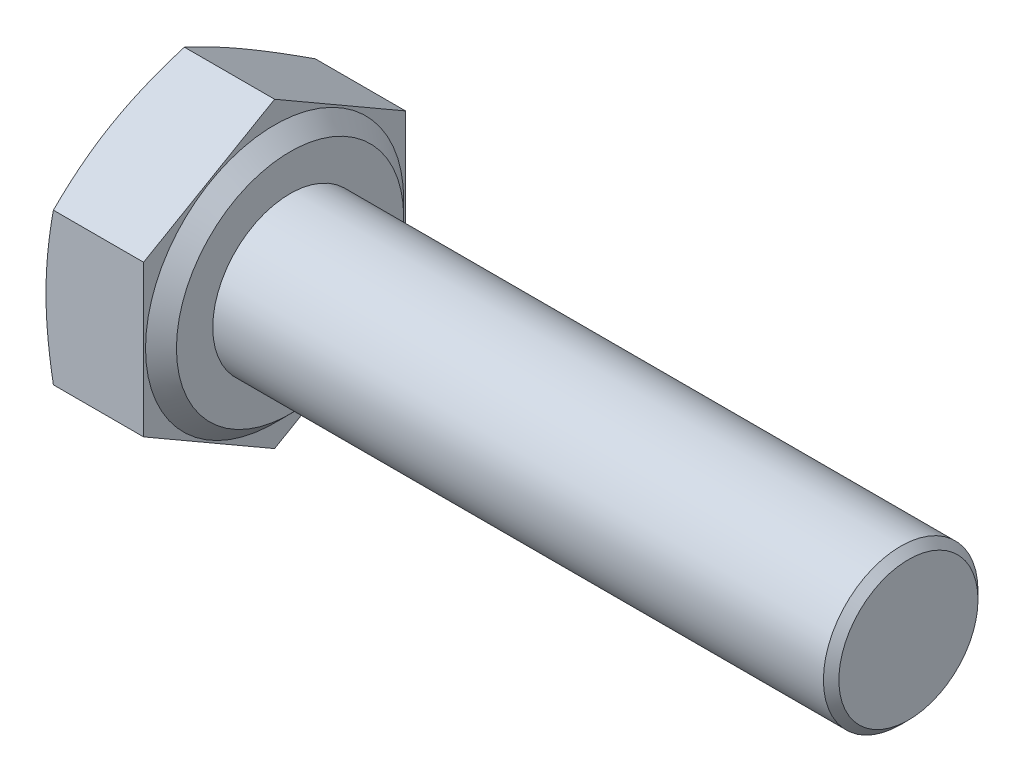
from build123d import *

# Parameters (mm, degrees)
BASEHEAD_DEPTH = 2.925
SKETCH5_R      = 2
BASEBODY_DEPTH = 16
CHAMFER1_SIZE  = 0.2


with BuildPart() as part:
    # Sketch2 → BaseHead (new body)
    with BuildSketch(Plane(origin=(0, 0, 0), x_dir=(0, 0, -1), z_dir=(1, 0, 0))):
        Polygon((3.39, -1.957217413), (3.39, 1.957217413), (0, 3.914434825), (-3.39, 1.957217413), (-3.39, -1.957217413), (0, -3.914434825), align=None)
    extrude(amount=BASEHEAD_DEPTH)

    # Sketch3 → BearingFace (revolve, cut)
    with BuildSketch(Plane.XY):
        Polygon((2.925, 3.914434825), (2.925, 2.94), (2.525, 3.34), (2.525, 3.914434825), align=None)
    revolve(axis=Axis((-0.957090588, 0, 0), (1, 0, 0)), mode=Mode.SUBTRACT)

    # Sketch4 → HeadChamfer (revolve, cut)
    with BuildSketch(Plane.XY):
        Polygon((0, 3.914434825), (0.190878666, 3.914434825), (0, 3.39), align=None)
    revolve(axis=Axis((-0.493528746, 0, 0), (1, 0, 0)), mode=Mode.SUBTRACT)

    # Sketch5 → BaseBody (add)
    with BuildSketch(Plane(origin=(2.925, 0, 0), x_dir=(0, 0, -1), z_dir=(1, 0, 0))):
        Circle(SKETCH5_R)
    extrude(amount=BASEBODY_DEPTH)

    # Chamfer1
    chamfer1_edges = [part.edges().sort_by_distance(p)[0] for p in [
        (18.925, 0, 2),
    ]]
    chamfer(chamfer1_edges, length=CHAMFER1_SIZE)


solid = part.part
